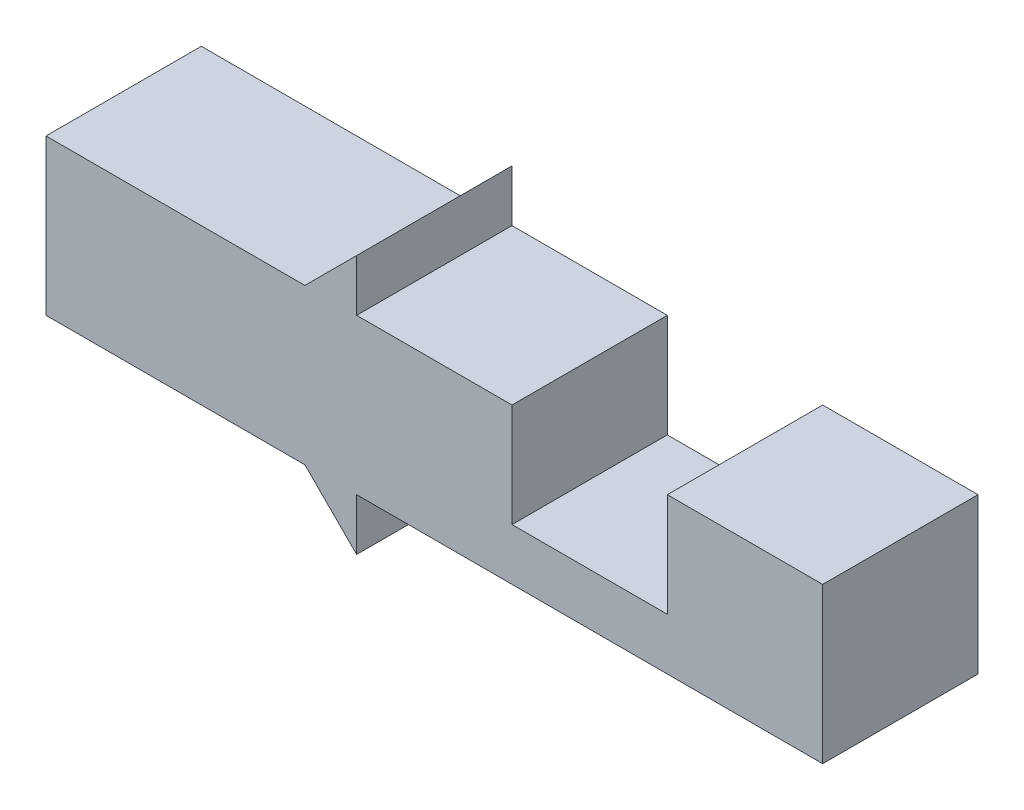
from build123d import *

# Parameters (mm, degrees)
BOSS_EXTRUDE1_DEPTH = 6


with BuildPart() as part:
    # Sketch1 → Boss-Extrude1 (new body)
    with BuildSketch(Plane.XY):
        Polygon((0, 0), (-18, 0), (-18, -2), (-20, 0), (-30, 0), (-30, 6), (-20, 6), (-18, 8), (-18, 6), (-12, 6), (-12, 2), (-6, 2), (-6, 6), (0, 6), align=None)
    extrude(amount=BOSS_EXTRUDE1_DEPTH)


solid = part.part
